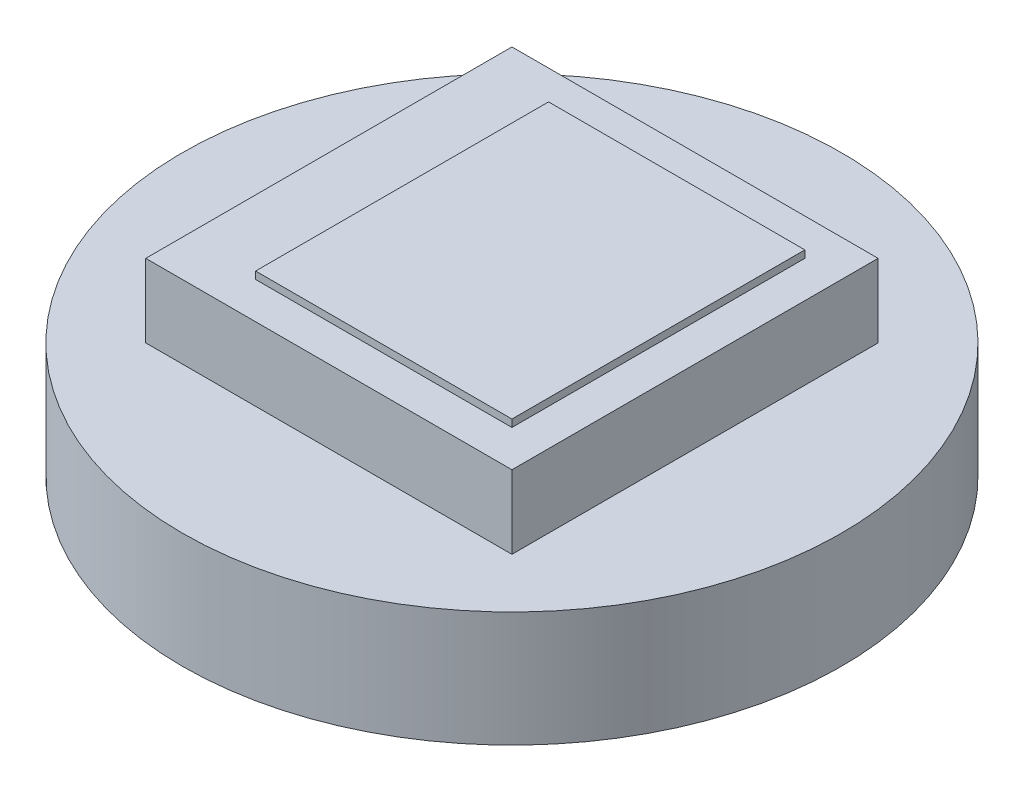
from build123d import *

# Parameters (mm, degrees)
SKETCH1_R           = 4.5
BOSS_EXTRUDE1_DEPTH = 1.5748
SKETCH2_W           = 5
SKETCH2_H           = 5
BOSS_EXTRUDE2_DEPTH = 1
SKETCH3_W           = 3.5
SKETCH3_H           = 4
BOSS_EXTRUDE3_DEPTH = 0.1


with BuildPart() as part:
    # Sketch1 → Boss-Extrude1 (new body)
    with BuildSketch(Plane(origin=(0, 0, 0), x_dir=(1, 0, 0), z_dir=(0, 1, 0))):
        Circle(SKETCH1_R)
    extrude(amount=BOSS_EXTRUDE1_DEPTH)

    # Sketch2 → Boss-Extrude2 (add)
    with BuildSketch(Plane(origin=(0, 1.5748, 0), x_dir=(1, 0, 0), z_dir=(0, 1, 0))):
        Rectangle(SKETCH2_W, SKETCH2_H)
    extrude(amount=BOSS_EXTRUDE2_DEPTH)

    # Sketch3 → Boss-Extrude3 (add)
    with BuildSketch(Plane(origin=(0, 2.5748, 0), x_dir=(1, 0, 0), z_dir=(0, 1, 0))):
        with Locations((0.25, 0)):
            Rectangle(SKETCH3_W, SKETCH3_H)
    extrude(amount=BOSS_EXTRUDE3_DEPTH)


solid = part.part
